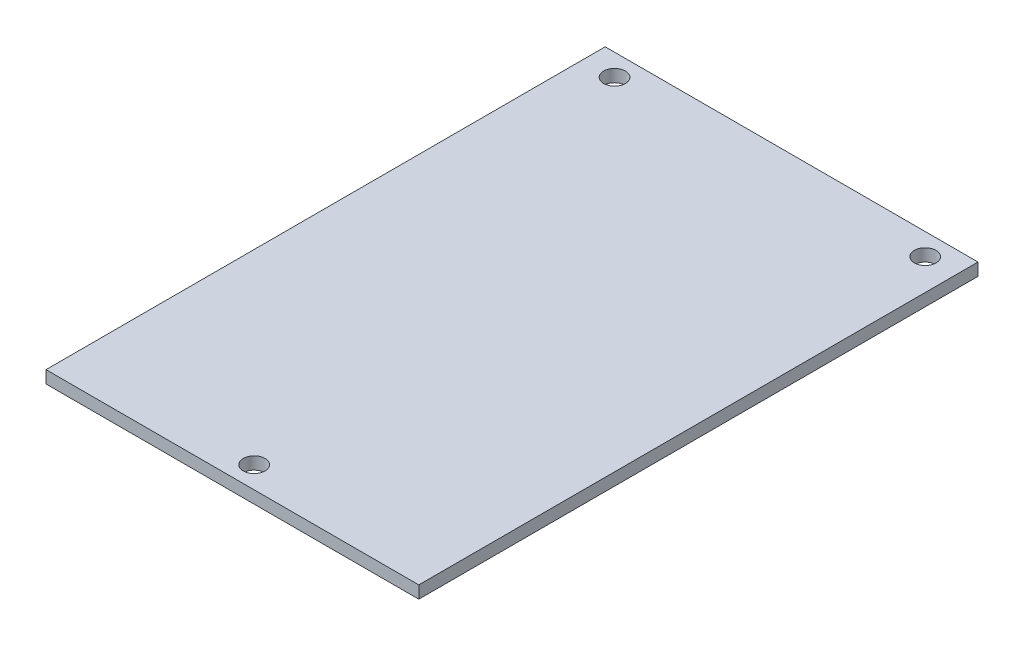
from build123d import *

# Parameters (mm, degrees)
SKETCH1_W           = 60
SKETCH1_H           = 90
BOSS_EXTRUDE1_DEPTH = 2
SKETCH2_R           = 1.75
CUT_EXTRUDE1_DEPTH  = 3


with BuildPart() as part:
    # Sketch1 → Boss-Extrude1 (new body)
    with BuildSketch(Plane(origin=(0, 0, 0), x_dir=(1, 0, 0), z_dir=(0, 1, 0))):
        Rectangle(SKETCH1_W, SKETCH1_H)
    extrude(amount=BOSS_EXTRUDE1_DEPTH)

    # Sketch2 → Cut-Extrude1 (cut, through all)
    with BuildSketch(Plane(origin=(0, 2, 0), x_dir=(1, 0, 0), z_dir=(0, 1, 0))):
        with Locations((-25, 41.5)):
            Circle(SKETCH2_R)
        with Locations((25, 41.5)):
            Circle(SKETCH2_R)
        with Locations((0, -41.5)):
            Circle(SKETCH2_R)
    extrude(amount=-CUT_EXTRUDE1_DEPTH, mode=Mode.SUBTRACT)


solid = part.part
